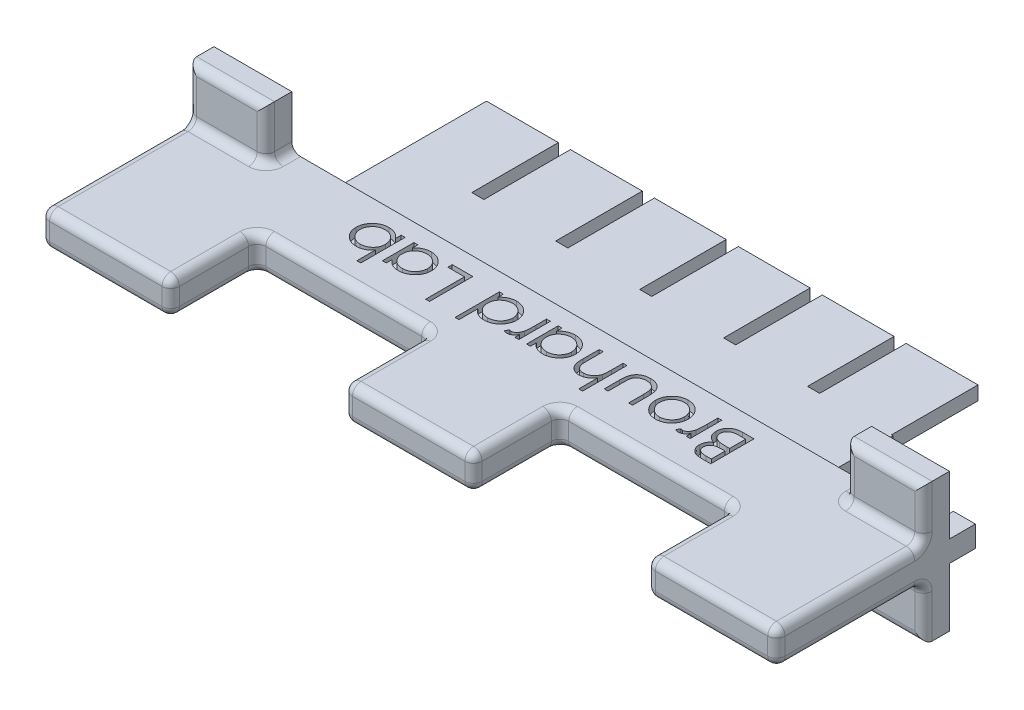
from build123d import *

# Parameters (mm, degrees)
SKETCH1_W           = 85
SKETCH1_H           = 4
BOSS_EXTRUDE1_DEPTH = 10
SKETCH2_W           = 15
SKETCH2_H           = 4
BOSS_EXTRUDE2_DEPTH = 10
SKETCH3_W           = 2.55
SKETCH3_H           = 2.45
BOSS_EXTRUDE3_DEPTH = 3
SKETCH4_W           = 57
SKETCH4_H           = 1.6
BOSS_EXTRUDE4_DEPTH = 7.5
SKETCH6_W           = 9
SKETCH6_H           = 6
BOSS_EXTRUDE6_DEPTH = 3
FILLET1_R           = 1
CUT_EXTRUDE1_DEPTH  = 1
SKETCH5_W           = 8.3
SKETCH5_H           = 1.6
BOSS_EXTRUDE5_DEPTH = 10


with BuildPart() as part:
    # Sketch1 → Boss-Extrude1 (new body)
    with BuildSketch(Plane.XY):
        Rectangle(SKETCH1_W, SKETCH1_H)
    extrude(amount=BOSS_EXTRUDE1_DEPTH)

    # Sketch2 → Boss-Extrude2 (add)
    with BuildSketch(Plane.XY.offset(10)):
        with Locations((-35, 0)):
            Rectangle(SKETCH2_W, SKETCH2_H)
        with Locations((35, 0)):
            Rectangle(SKETCH2_W, SKETCH2_H)
        Rectangle(SKETCH2_W, SKETCH2_H)
    extrude(amount=BOSS_EXTRUDE2_DEPTH)

    # Sketch3 → Boss-Extrude3 (add)
    with BuildSketch(Plane(origin=(0, 0, 0), x_dir=(-1, 0, 0), z_dir=(0, 0, -1))):
        with Locations((-41.225, 0)):
            Rectangle(SKETCH3_W, SKETCH3_H)
        with Locations((41.225, 0)):
            Rectangle(SKETCH3_W, SKETCH3_H)
    extrude(amount=BOSS_EXTRUDE3_DEPTH)

    # Sketch4 → Boss-Extrude4 (add)
    with BuildSketch(Plane(origin=(0, 0, 0), x_dir=(-1, 0, 0), z_dir=(0, 0, -1))):
        Rectangle(SKETCH4_W, SKETCH4_H)
    extrude(amount=BOSS_EXTRUDE4_DEPTH)

    # Sketch6 → Boss-Extrude6 (add)
    with BuildSketch(Plane(origin=(0, 0, 0), x_dir=(-1, 0, 0), z_dir=(0, 0, -1))):
        with Locations((38, -5)):
            Rectangle(SKETCH6_W, SKETCH6_H)
        with Locations((38, 5)):
            Rectangle(SKETCH6_W, SKETCH6_H)
        with Locations((-38, -5)):
            Rectangle(SKETCH6_W, SKETCH6_H)
        with Locations((-38, 5)):
            Rectangle(SKETCH6_W, SKETCH6_H)
    extrude(amount=-BOSS_EXTRUDE6_DEPTH)

    # Fillet1
    fillet1_edges = [part.edges().sort_by_distance(p)[0] for p in [
        (-42.5, 5, 3),
        (-38, 2, 3),
        (-33.5, 5, 3),
        (-33.5, 2, 1.5),
        (-38, 8, 3),
        (42.5, -5, 3),
        (38, -2, 3),
        (33.5, -5, 3),
        (33.5, -2, 1.5),
        (38, -8, 3),
        (42.5, 5, 3),
        (38, 8, 3),
        (33.5, 5, 3),
        (38, 2, 3),
        (33.5, 2, 1.5),
        (-17.5, -2, 10),
        (-27.5, 0, 10),
        (-27.5, -2, 15),
        (-27.5, 2, 15),
        (-42.5, 0, 20),
        (-35, -2, 20),
        (-27.5, 0, 20),
        (-35, 2, 20),
        (17.5, 2, 10),
        (27.5, 0, 10),
        (27.5, 2, 15),
        (27.5, -2, 15),
        (42.5, 0, 20),
        (35, 2, 20),
        (27.5, 0, 20),
        (35, -2, 20),
        (17.5, -2, 10),
        (-17.5, 2, 10),
        (7.5, 0, 10),
        (7.5, -2, 15),
        (7.5, 2, 15),
        (-7.5, 0, 10),
        (-7.5, 2, 15),
        (-7.5, -2, 15),
        (7.5, 0, 20),
        (0, 2, 20),
        (-7.5, 0, 20),
        (0, -2, 20),
        (42.5, -2, 11.5),
        (-42.5, -2, 11.5),
        (-42.5, 2, 11.5),
        (42.5, 2, 11.5),
        (-42.5, -5, 3),
        (-38, -8, 3),
        (-33.5, -5, 3),
        (-38, -2, 3),
        (-33.5, -2, 1.5),
    ]]
    fillet(fillet1_edges, radius=FILLET1_R)

    # Sketch8 → Cut-Extrude1 (cut)
    with BuildSketch(Plane(origin=(0, 2, 0), x_dir=(1, 0, 0), z_dir=(0, 1, 0))):
        with BuildLine():
            Line((21.955128205, -7.045024133), (20.979567308, -7.045024133))
            add(Edge.make_bspline(
                [(20.979567308, -7.045024133), (20.931811586, -7.044777014), (20.839249111, -7.044298035), (20.704660144, -7.036696988), (20.578554958, -7.026592114), (20.461156398, -7.009641733), (20.351700568, -6.992066423), (20.251298675, -6.966270076), (20.159109728, -6.937777071), (20.048409672, -6.893936716), (19.92280529, -6.825852091), (19.787804083, -6.724876123), (19.670452795, -6.603814091), (19.570669416, -6.465854357), (19.490591132, -6.314083016), (19.43339094, -6.151765477), (19.396643358, -5.981632539), (19.392911608, -5.864990679), (19.391025641, -5.806041761)],
                knots=[0, 0, 0, 0, 0.000143243, 0.000277641, 0.000404323, 0.000522601, 0.000633422, 0.000736665, 0.000833282, 0.000922745, 0.001093491, 0.001260157, 0.001426607, 0.001597303, 0.001769346, 0.001939468, 0.002112331, 0.002288957, 0.002288957, 0.002288957, 0.002288957], degree=3))
            add(Edge.make_bspline(
                [(19.391025641, -5.806041761), (19.392566125, -5.750816773), (19.395593321, -5.642294463), (19.425166581, -5.484100137), (19.4698067, -5.333038737), (19.534225102, -5.190566035), (19.616363978, -5.057933935), (19.716298264, -4.937404803), (19.834792937, -4.831345021), (19.923759393, -4.772321243), (19.968950321, -4.742339838)],
                knots=[0, 0, 0, 0, 0.00016551, 0.000325243, 0.000481139, 0.000637145, 0.000792791, 0.000947835, 0.001105294, 0.001267844, 0.001267844, 0.001267844, 0.001267844], degree=3))
            add(Edge.make_bspline(
                [(19.968950321, -4.742339838), (19.912145679, -4.720542475), (19.803464327, -4.678838718), (19.653711211, -4.604821394), (19.524645211, -4.524933301), (19.41460302, -4.438588883), (19.32239544, -4.34296875), (19.240253224, -4.240591123), (19.170541651, -4.127890536), (19.111062126, -4.007309158), (19.063944891, -3.879485542), (19.031238978, -3.745375962), (19.010496783, -3.606499394), (19.007784363, -3.512111636), (19.006410256, -3.464294967)],
                knots=[0, 0, 0, 0, 0.000182459, 0.00034909, 0.000500276, 0.000637148, 0.000767471, 0.00089793, 0.001030217, 0.001164151, 0.001300726, 0.001437979, 0.001577644, 0.001721044, 0.001721044, 0.001721044, 0.001721044], degree=3))
            add(Edge.make_bspline(
                [(19.006410256, -3.464294967), (19.007805885, -3.41548523), (19.010551822, -3.319450707), (19.030807012, -3.178370784), (19.065112767, -3.043553694), (19.112331393, -2.914102037), (19.173883248, -2.790773975), (19.248244287, -2.672600284), (19.337493216, -2.561332318), (19.437996289, -2.45535544), (19.550128803, -2.358444164), (19.673690061, -2.2751618), (19.805513315, -2.203227398), (19.947403728, -2.145396174), (20.098354491, -2.100124903), (20.258400966, -2.068824422), (20.427452272, -2.047649449), (20.543467886, -2.045914087), (20.602964744, -2.045024133)],
                knots=[0, 0, 0, 0, 0.000146402, 0.00028805, 0.000426518, 0.000563092, 0.000700608, 0.000839267, 0.000981145, 0.001127794, 0.001276955, 0.001424748, 0.00157399, 0.001726698, 0.001883553, 0.002046002, 0.002215459, 0.002393845, 0.002393845, 0.002393845, 0.002393845], degree=3))
            Line((20.602964744, -2.045024133), (21.955128205, -2.045024133))
            Line((21.955128205, -2.045024133), (21.955128205, -7.045024133))
        make_face()
        with BuildLine():
            Line((21.506410256, -6.53220362), (21.506410256, -4.929639518))
            Line((21.506410256, -4.929639518), (21.204927885, -4.929639518))
            add(Edge.make_bspline(
                [(21.204927885, -4.929639518), (21.16085778, -4.930206082), (21.075705357, -4.9313008), (20.952063514, -4.934535484), (20.837581625, -4.943196106), (20.731865233, -4.952356158), (20.635622811, -4.966460704), (20.548532434, -4.983720889), (20.469810894, -5.00181496), (20.379071632, -5.032675643), (20.276157749, -5.077807077), (20.16721677, -5.149562501), (20.069164992, -5.232639769), (19.988277934, -5.331182392), (19.920936523, -5.437599512), (19.875598165, -5.552684686), (19.843986577, -5.672472047), (19.841172407, -5.755083607), (19.83974359, -5.797027338)],
                knots=[0, 0, 0, 0, 0.000132227, 0.000255489, 0.000370952, 0.000476596, 0.000573767, 0.000662554, 0.000742964, 0.000815812, 0.000949851, 0.001078759, 0.001205868, 0.001333854, 0.001459773, 0.001581973, 0.001703679, 0.001829203, 0.001829203, 0.001829203, 0.001829203], degree=3))
            add(Edge.make_bspline(
                [(19.83974359, -5.797027338), (19.840440447, -5.824795004), (19.841807408, -5.879264312), (19.85469429, -5.958622966), (19.872478035, -6.034141042), (19.901807859, -6.103782707), (19.936556119, -6.169993364), (19.98109509, -6.230681546), (20.03245262, -6.287491301), (20.092329064, -6.338899898), (20.160479658, -6.385396007), (20.239063252, -6.424101797), (20.325943351, -6.458499162), (20.422931675, -6.48457317), (20.528096305, -6.507209559), (20.643041681, -6.521483941), (20.767075062, -6.530654029), (20.853013063, -6.531675569), (20.897435897, -6.53220362)],
                knots=[0, 0, 0, 0, 8.3229e-05, 0.000163264, 0.000240757, 0.000315341, 0.000389283, 0.000464617, 0.000540481, 0.000618594, 0.000700823, 0.000787274, 0.000880832, 0.000980716, 0.001088168, 0.001203335, 0.00132786, 0.001461107, 0.001461107, 0.001461107, 0.001461107], degree=3))
            Line((20.897435897, -6.53220362), (21.506410256, -6.53220362))
        make_face(mode=Mode.SUBTRACT)
        with BuildLine():
            Line((21.506410256, -4.416819005), (21.506410256, -2.557844646))
            Line((21.506410256, -2.557844646), (20.867387821, -2.557844646))
            add(Edge.make_bspline(
                [(20.867387821, -2.557844646), (20.82165107, -2.558445571), (20.733499514, -2.559603775), (20.606126985, -2.562352033), (20.48869926, -2.57254806), (20.380238634, -2.582323383), (20.281246941, -2.598293401), (20.190761319, -2.61375789), (20.110848501, -2.63651465), (20.017345889, -2.667828353), (19.912764158, -2.717871803), (19.798555972, -2.791464981), (19.697962318, -2.881106895), (19.612615651, -2.984324471), (19.541653639, -3.095395221), (19.492561941, -3.214537751), (19.460753316, -3.337772506), (19.457007017, -3.422035912), (19.455128205, -3.464294967)],
                knots=[0, 0, 0, 0, 0.000137234, 0.000264501, 0.000382034, 0.000490767, 0.000591058, 0.000682796, 0.000765899, 0.000840017, 0.000978463, 0.001112367, 0.001246451, 0.001380849, 0.001513136, 0.001640186, 0.001766022, 0.001892621, 0.001892621, 0.001892621, 0.001892621], degree=3))
            add(Edge.make_bspline(
                [(19.455128205, -3.464294967), (19.455511728, -3.490717987), (19.456272588, -3.543137822), (19.468232548, -3.620102651), (19.484829912, -3.695025725), (19.509289766, -3.766889341), (19.538879538, -3.836930979), (19.577915987, -3.902871611), (19.621948812, -3.967518228), (19.690148998, -4.050208407), (19.790699472, -4.144331407), (19.933635519, -4.235332182), (20.095250073, -4.309910154), (20.212743455, -4.341437989), (20.2734375, -4.357724454)],
                knots=[0, 0, 0, 0, 7.9184e-05, 0.00015709, 0.000233139, 0.000309156, 0.000384516, 0.000460796, 0.000538586, 0.000618995, 0.000781989, 0.000949233, 0.001125381, 0.001313608, 0.001313608, 0.001313608, 0.001313608], degree=3))
            add(Edge.make_bspline(
                [(20.2734375, -4.357724454), (20.297764757, -4.36266062), (20.350511268, -4.373363246), (20.436522534, -4.384653585), (20.535045896, -4.394781387), (20.645660247, -4.402076233), (20.768805516, -4.409907124), (20.904442139, -4.412844185), (21.052666008, -4.416429024), (21.15551238, -4.416685686), (21.208934295, -4.416819005)],
                knots=[0, 0, 0, 0, 7.4449e-05, 0.000161422, 0.000260089, 0.000371555, 0.000493951, 0.000630228, 0.000778496, 0.000938755, 0.000938755, 0.000938755, 0.000938755], degree=3))
            Line((21.208934295, -4.416819005), (21.506410256, -4.416819005))
        make_face(mode=Mode.SUBTRACT)
        with BuildLine():
            Line((18.237179487, -5.698870287), (17.788461538, -5.698870287))
            Line((17.788461538, -5.698870287), (17.788461538, -5.16100971))
            add(Edge.make_bspline(
                [(17.788461538, -5.16100971), (17.755359908, -5.211117117), (17.692053298, -5.306947144), (17.586273377, -5.43343718), (17.479111393, -5.53983342), (17.366921794, -5.622588498), (17.252557594, -5.685650706), (17.136357118, -5.730343447), (17.017481778, -5.757585182), (16.937237879, -5.761174556), (16.897035256, -5.762972851)],
                knots=[0, 0, 0, 0, 0.000180032, 0.00034431, 0.000493764, 0.000631989, 0.000761087, 0.000884414, 0.00100446, 0.00112499, 0.00112499, 0.00112499, 0.00112499], degree=3))
            add(Edge.make_bspline(
                [(16.897035256, -5.762972851), (16.865844687, -5.761310147), (16.801992924, -5.757906343), (16.705041331, -5.732794344), (16.604739598, -5.694222955), (16.540012887, -5.657063647), (16.506410256, -5.637772531)],
                knots=[0, 0, 0, 0, 9.3493e-05, 0.000191394, 0.000298902, 0.000414971, 0.000414971, 0.000414971, 0.000414971], degree=3))
            Line((16.506410256, -5.637772531), (16.752804487, -5.249150736))
            add(Edge.make_bspline(
                [(16.752804487, -5.249150736), (16.774388803, -5.258779687), (16.815359967, -5.277057281), (16.875295061, -5.298688724), (16.930554114, -5.311425747), (16.965759197, -5.313355343), (16.982171474, -5.314254902)],
                knots=[0, 0, 0, 0, 7.0888e-05, 0.000134558, 0.000190943, 0.000240184, 0.000240184, 0.000240184, 0.000240184], degree=3))
            add(Edge.make_bspline(
                [(16.982171474, -5.314254902), (17.018552318, -5.311962095), (17.092095887, -5.307327204), (17.199553418, -5.267726819), (17.305221395, -5.20820996), (17.387285817, -5.138004944), (17.451536641, -5.071852679), (17.497773588, -5.013639038), (17.539299542, -4.947803919), (17.579572406, -4.876841023), (17.616991286, -4.798984205), (17.65042989, -4.714102186), (17.681701622, -4.622897124), (17.699312387, -4.559480067), (17.708333333, -4.526995287)],
                knots=[0, 0, 0, 0, 0.000108839, 0.000220017, 0.000339778, 0.000471355, 0.000542193, 0.000616339, 0.000693851, 0.000775474, 0.000861039, 0.000952734, 0.001049023, 0.001150145, 0.001150145, 0.001150145, 0.001150145], degree=3))
            add(Edge.make_bspline(
                [(17.708333333, -4.526995287), (17.715105579, -4.4980295), (17.73018081, -4.433550753), (17.744447085, -4.325868753), (17.75911049, -4.198727857), (17.769124119, -4.051980366), (17.778583328, -3.885062178), (17.783808984, -3.698693379), (17.788295276, -3.492361731), (17.78840435, -3.348446216), (17.788461538, -3.272988877)],
                knots=[0, 0, 0, 0, 8.9193e-05, 0.000198547, 0.000325526, 0.000473173, 0.000639683, 0.000827079, 0.001032447, 0.001258811, 0.001258811, 0.001258811, 0.001258811], degree=3))
            Line((17.788461538, -3.272988877), (17.788461538, -2.045024133))
            Line((17.788461538, -2.045024133), (18.237179487, -2.045024133))
            Line((18.237179487, -2.045024133), (18.237179487, -5.698870287))
        make_face()
        with BuildLine():
            add(Edge.make_bspline(
                [(14.29286859, -5.762972851), (14.224307927, -5.761517291), (14.089877222, -5.758663293), (13.893032913, -5.728009819), (13.705327588, -5.681525783), (13.525956048, -5.616093456), (13.356402056, -5.530243686), (13.195151776, -5.426425769), (13.042528278, -5.303937317), (12.951070622, -5.209132095), (12.904647436, -5.16100971)],
                knots=[0, 0, 0, 0, 0.000205526, 0.000402987, 0.000596112, 0.000784972, 0.000974447, 0.001165038, 0.001359476, 0.001559909, 0.001559909, 0.001559909, 0.001559909], degree=3))
            add(Edge.make_bspline(
                [(12.904647436, -5.16100971), (12.864673216, -5.11498973), (12.785498387, -5.023840384), (12.683975931, -4.876046652), (12.59651656, -4.722989365), (12.526426616, -4.562636041), (12.471162296, -4.396386511), (12.431925587, -4.223669352), (12.408587109, -4.044865999), (12.405440013, -3.923431945), (12.403846154, -3.861931185)],
                knots=[0, 0, 0, 0, 0.000182745, 0.000361954, 0.000536876, 0.000710881, 0.000886036, 0.001061708, 0.001241475, 0.001425944, 0.001425944, 0.001425944, 0.001425944], degree=3))
            add(Edge.make_bspline(
                [(12.403846154, -3.861931185), (12.405248064, -3.800073959), (12.408018305, -3.677841197), (12.434223472, -3.497813533), (12.474982163, -3.323249495), (12.533313369, -3.154879952), (12.608110636, -2.992190127), (12.699383171, -2.835891045), (12.807770716, -2.685672654), (12.930635425, -2.542816985), (13.066416897, -2.411135675), (13.21375075, -2.296436369), (13.369848434, -2.197755629), (13.536840837, -2.119375683), (13.712350874, -2.056195988), (13.8974949, -2.012629522), (14.09210775, -1.986052796), (14.225006973, -1.982656037), (14.29286859, -1.980921569)],
                knots=[0, 0, 0, 0, 0.00018547, 0.000366497, 0.000544574, 0.000722589, 0.000900065, 0.001080956, 0.001264689, 0.001455025, 0.001645575, 0.001831106, 0.002014249, 0.002198383, 0.002383395, 0.002572886, 0.002767942, 0.002971467, 0.002971467, 0.002971467, 0.002971467], degree=3))
            add(Edge.make_bspline(
                [(14.29286859, -1.980921569), (14.361059424, -1.982670388), (14.494614618, -1.986095539), (14.689960267, -2.012431829), (14.875883807, -2.056661478), (15.052224048, -2.118593533), (15.219215773, -2.198399418), (15.37588985, -2.296052412), (15.523293198, -2.411193757), (15.65911724, -2.542801247), (15.781970535, -2.685676709), (15.890361026, -2.835889993), (15.981632796, -2.992190401), (16.056430263, -3.154879879), (16.114761415, -3.323249515), (16.155520121, -3.497813528), (16.181725284, -3.677841198), (16.184495525, -3.80007396), (16.185897436, -3.861931185)],
                knots=[0, 0, 0, 0, 0.000204526, 0.000400574, 0.000590065, 0.000776965, 0.000960195, 0.001144188, 0.00132972, 0.001520269, 0.001710605, 0.001894339, 0.00207523, 0.002252706, 0.002430721, 0.002608798, 0.002789825, 0.002975294, 0.002975294, 0.002975294, 0.002975294], degree=3))
            add(Edge.make_bspline(
                [(16.185897436, -3.861931185), (16.184296519, -3.923099043), (16.18112698, -4.044200892), (16.157756652, -4.22264832), (16.118946868, -4.394836864), (16.062916427, -4.560178538), (15.992956591, -4.720146456), (15.90637746, -4.873764934), (15.803872945, -5.02091287), (15.725005709, -5.111941341), (15.685096154, -5.158004902)],
                knots=[0, 0, 0, 0, 0.000183468, 0.000363236, 0.000538908, 0.000712162, 0.000886167, 0.001061962, 0.001240348, 0.001423094, 0.001423094, 0.001423094, 0.001423094], degree=3))
            add(Edge.make_bspline(
                [(15.685096154, -5.158004902), (15.638739114, -5.20653651), (15.547569839, -5.301982456), (15.394241809, -5.424229232), (15.233685171, -5.529446865), (15.063037498, -5.615253429), (14.883167202, -5.681407061), (14.694066814, -5.728226774), (14.496506031, -5.758527704), (14.361424213, -5.761476369), (14.29286859, -5.762972851)],
                knots=[0, 0, 0, 0, 0.00020114, 0.000395577, 0.000586713, 0.000776188, 0.000967274, 0.001160399, 0.001359841, 0.001565367, 0.001565367, 0.001565367, 0.001565367], degree=3))
        make_face()
        with BuildLine():
            add(Edge.make_bspline(
                [(14.294871795, -5.314254902), (14.343354042, -5.31287684), (14.439066976, -5.310156289), (14.579952881, -5.289466071), (14.715578773, -5.256679949), (14.84621924, -5.210117374), (14.971369132, -5.149920796), (15.091165691, -5.076401027), (15.205288814, -4.989167289), (15.312855022, -4.88995037), (15.412753003, -4.782192755), (15.499001382, -4.666286529), (15.572889716, -4.545452386), (15.633262525, -4.419007361), (15.679580189, -4.286604065), (15.712397714, -4.149000046), (15.733127199, -4.005785755), (15.735814091, -3.908409845), (15.737179487, -3.858926377)],
                knots=[0, 0, 0, 0, 0.000145402, 0.00028705, 0.000426247, 0.000563423, 0.000702299, 0.000842129, 0.000984361, 0.00113252, 0.001280679, 0.00142451, 0.001565195, 0.001704975, 0.001844039, 0.001985183, 0.002128814, 0.002277217, 0.002277217, 0.002277217, 0.002277217], degree=3))
            add(Edge.make_bspline(
                [(15.737179487, -3.858926377), (15.734890082, -3.794992084), (15.730346041, -3.668094469), (15.693206633, -3.48126298), (15.631516344, -3.301562306), (15.546449569, -3.131156088), (15.441687276, -2.973216762), (15.31918926, -2.831196974), (15.177261944, -2.710573578), (15.020738225, -2.609127271), (14.851836243, -2.5292384), (14.673387712, -2.471947456), (14.487017459, -2.435206285), (14.359480893, -2.431511347), (14.294871795, -2.429639518)],
                knots=[0, 0, 0, 0, 0.000191683, 0.000380455, 0.000568919, 0.000760186, 0.000950198, 0.001136194, 0.00132088, 0.001507019, 0.001694298, 0.001879594, 0.002068178, 0.002261801, 0.002261801, 0.002261801, 0.002261801], degree=3))
            add(Edge.make_bspline(
                [(14.294871795, -2.429639518), (14.23025898, -2.431500504), (14.102715078, -2.435174039), (13.916085515, -2.472133599), (13.737147914, -2.528989279), (13.568070317, -2.609217501), (13.411475317, -2.710190138), (13.270561459, -2.831884154), (13.147008507, -2.972843418), (13.04214248, -3.130946672), (12.958446366, -3.301827223), (12.896465966, -3.481229869), (12.859415628, -3.668102902), (12.854859565, -3.794994909), (12.852564103, -3.858926377)],
                knots=[0, 0, 0, 0, 0.000193623, 0.000382206, 0.000568456, 0.000755734, 0.000941873, 0.001125801, 0.001312456, 0.001502468, 0.001693291, 0.001881755, 0.002070527, 0.00226221, 0.00226221, 0.00226221, 0.00226221], degree=3))
            add(Edge.make_bspline(
                [(12.852564103, -3.858926377), (12.85391927, -3.908413822), (12.856586033, -4.00579756), (12.877461924, -4.148954918), (12.909764333, -4.286878115), (12.958078967, -4.418473367), (13.016348399, -4.546067931), (13.092028067, -4.665924648), (13.177874936, -4.782266279), (13.277956043, -4.889885455), (13.385510177, -4.98952979), (13.500490643, -5.076083255), (13.620342842, -5.149962779), (13.745532283, -5.210124787), (13.875877117, -5.256500729), (14.011091241, -5.289608892), (14.151353237, -5.310080851), (14.246726302, -5.312854653), (14.294871795, -5.314254902)],
                knots=[0, 0, 0, 0, 0.000148403, 0.000292034, 0.000433178, 0.000572578, 0.00071193, 0.000853138, 0.000996969, 0.001145128, 0.001293287, 0.001436317, 0.001576147, 0.001715023, 0.001852199, 0.001990424, 0.002132072, 0.002276473, 0.002276473, 0.002276473, 0.002276473], degree=3))
        make_face(mode=Mode.SUBTRACT)
        with BuildLine():
            Line((11.570512821, -5.698870287), (11.121794872, -5.698870287))
            Line((11.121794872, -5.698870287), (11.121794872, -4.004158749))
            add(Edge.make_bspline(
                [(11.121794872, -4.004158749), (11.121592151, -3.954411964), (11.121204354, -3.859248695), (11.118574439, -3.722312714), (11.112388591, -3.597431696), (11.104654555, -3.484533501), (11.094708647, -3.383637227), (11.082875275, -3.295095289), (11.069648958, -3.217903597), (11.056702224, -3.171413089), (11.05068109, -3.149791761)],
                knots=[0, 0, 0, 0, 0.000149242, 0.000285493, 0.000410838, 0.000524302, 0.000624962, 0.000714911, 0.000792314, 0.000859608, 0.000859608, 0.000859608, 0.000859608], degree=3))
            add(Edge.make_bspline(
                [(11.05068109, -3.149791761), (11.041021805, -3.122616307), (11.02190405, -3.06883037), (10.987228565, -2.991130691), (10.944327515, -2.919170094), (10.897397624, -2.850149082), (10.843207537, -2.786203671), (10.78254961, -2.72691621), (10.716500508, -2.671595092), (10.619751651, -2.6048734), (10.487494763, -2.534263345), (10.314242396, -2.472488378), (10.126045943, -2.436112097), (9.995820794, -2.431836921), (9.928886218, -2.429639518)],
                knots=[0, 0, 0, 0, 8.6516e-05, 0.000171232, 0.000254721, 0.000337515, 0.000421387, 0.00050567, 0.000591721, 0.00067952, 0.000857864, 0.001039709, 0.001229465, 0.001430146, 0.001430146, 0.001430146, 0.001430146], degree=3))
            add(Edge.make_bspline(
                [(9.928886218, -2.429639518), (9.86194316, -2.431828713), (9.732748927, -2.436053669), (9.546518851, -2.471939165), (9.375968682, -2.530483395), (9.223089747, -2.613350563), (9.088841758, -2.714376404), (8.976981124, -2.832969142), (8.884684323, -2.965323174), (8.844385248, -3.064072442), (8.82411859, -3.113734069)],
                knots=[0, 0, 0, 0, 0.000200681, 0.000387296, 0.000566586, 0.000739571, 0.000906841, 0.001068376, 0.001227003, 0.001387484, 0.001387484, 0.001387484, 0.001387484], degree=3))
            add(Edge.make_bspline(
                [(8.82411859, -3.113734069), (8.8181224, -3.1336855), (8.80486629, -3.177793242), (8.790725551, -3.252630176), (8.777460105, -3.341789135), (8.768616165, -3.446206446), (8.758522511, -3.564961319), (8.755037146, -3.698667884), (8.750059864, -3.846538026), (8.750020544, -3.950065981), (8.75, -4.004158749)],
                knots=[0, 0, 0, 0, 6.2462e-05, 0.000138088, 0.000228176, 0.000332823, 0.000452355, 0.000585662, 0.000733953, 0.000896216, 0.000896216, 0.000896216, 0.000896216], degree=3))
            Line((8.75, -4.004158749), (8.75, -5.698870287))
            Line((8.75, -5.698870287), (8.301282051, -5.698870287))
            Line((8.301282051, -5.698870287), (8.301282051, -3.920024133))
            add(Edge.make_bspline(
                [(8.301282051, -3.920024133), (8.30191531, -3.859585653), (8.303143917, -3.742326733), (8.310980731, -3.571916291), (8.324614367, -3.412799073), (8.344773775, -3.265462167), (8.369229918, -3.129870336), (8.400154934, -3.00598092), (8.437277048, -2.893621613), (8.479165629, -2.791153018), (8.528529202, -2.698158121), (8.581390514, -2.610389295), (8.640827886, -2.528135886), (8.705652894, -2.450645369), (8.777741804, -2.379798189), (8.85333008, -2.311961845), (8.93610888, -2.251321381), (9.023288539, -2.194646502), (9.117066908, -2.144351467), (9.216637391, -2.100832577), (9.321894658, -2.063022013), (9.433003103, -2.033803946), (9.549897573, -2.009153726), (9.67242881, -1.992746928), (9.800829998, -1.982271357), (9.888132562, -1.981379054), (9.932892628, -1.980921569)],
                knots=[0, 0, 0, 0, 0.000181315, 0.000351776, 0.000511647, 0.000660239, 0.000797754, 0.000924804, 0.001042946, 0.001152506, 0.001256441, 0.001358477, 0.001459659, 0.001560587, 0.001661157, 0.001762636, 0.001865001, 0.001968632, 0.00207439, 0.002183817, 0.002294379, 0.002409546, 0.002528193, 0.002652561, 0.002780158, 0.002914407, 0.002914407, 0.002914407, 0.002914407], degree=3))
            add(Edge.make_bspline(
                [(9.932892628, -1.980921569), (9.977316456, -1.981406186), (10.064613414, -1.982358504), (10.192711845, -1.992570693), (10.315507575, -2.00940504), (10.432494069, -2.033606354), (10.544142851, -2.063257518), (10.649911875, -2.100566743), (10.749934706, -2.144600485), (10.84442655, -2.194693497), (10.933073912, -2.251115088), (11.015677547, -2.313213364), (11.093710062, -2.379368112), (11.165005381, -2.451835522), (11.23008642, -2.530073038), (11.28923533, -2.613729086), (11.343463789, -2.701858176), (11.392537938, -2.79623559), (11.434697953, -2.899909467), (11.471919623, -3.014619732), (11.502363426, -3.141623289), (11.527138371, -3.28081177), (11.547069003, -3.431518969), (11.560906348, -3.594616706), (11.568643249, -3.769707694), (11.569876194, -3.890636109), (11.570512821, -3.953077018)],
                knots=[0, 0, 0, 0, 0.000133247, 0.000261843, 0.000385219, 0.000504847, 0.000620013, 0.00073152, 0.000840947, 0.000947589, 0.001052063, 0.001155829, 0.001257407, 0.001358687, 0.001460383, 0.00156238, 0.001665793, 0.001770617, 0.001881102, 0.002001148, 0.002132087, 0.002272558, 0.00242512, 0.002587985, 0.002763448, 0.002950772, 0.002950772, 0.002950772, 0.002950772], degree=3))
            Line((11.570512821, -3.953077018), (11.570512821, -5.698870287))
        make_face()
        with BuildLine():
            Line((7.275641026, -7.173229261), (6.826923077, -7.173229261))
            Line((6.826923077, -7.173229261), (6.826923077, -5.00876612))
            add(Edge.make_bspline(
                [(6.826923077, -5.00876612), (6.778678808, -5.068888094), (6.684893793, -5.185762911), (6.528113976, -5.339904506), (6.36474826, -5.471196487), (6.193410264, -5.578408978), (6.014828183, -5.661579829), (5.828563194, -5.719766634), (5.635090167, -5.756050633), (5.503296595, -5.760649137), (5.436698718, -5.762972851)],
                knots=[0, 0, 0, 0, 0.000231093, 0.000449235, 0.000658061, 0.000858722, 0.001054107, 0.001247341, 0.001442817, 0.001642498, 0.001642498, 0.001642498, 0.001642498], degree=3))
            add(Edge.make_bspline(
                [(5.436698718, -5.762972851), (5.369051259, -5.760620551), (5.236582495, -5.756014225), (5.044402774, -5.715426657), (4.863656734, -5.651196128), (4.696758785, -5.560924861), (4.546286047, -5.448841659), (4.415775284, -5.31738737), (4.306291209, -5.168293369), (4.233038251, -5.029320354), (4.185028125, -4.905733149), (4.154679673, -4.799671692), (4.128934509, -4.68150037), (4.106507375, -4.551264166), (4.091559078, -4.408342759), (4.079552578, -4.253379458), (4.071014758, -4.086383599), (4.070683898, -3.970783239), (4.070512821, -3.91100971)],
                knots=[0, 0, 0, 0, 0.000202742, 0.000397014, 0.000586474, 0.000776485, 0.000963986, 0.001147421, 0.001330122, 0.001516953, 0.001616837, 0.001727454, 0.0018475, 0.00197956, 0.002123683, 0.002278397, 0.002445857, 0.002625155, 0.002625155, 0.002625155, 0.002625155], degree=3))
            Line((4.070512821, -3.91100971), (4.070512821, -2.045024133))
            Line((4.070512821, -2.045024133), (4.519230769, -2.045024133))
            Line((4.519230769, -2.045024133), (4.519230769, -3.763774133))
            add(Edge.make_bspline(
                [(4.519230769, -3.763774133), (4.519501544, -3.813520868), (4.52001949, -3.908677905), (4.521752659, -4.044914373), (4.525533642, -4.16814974), (4.531869413, -4.278639822), (4.53824468, -4.376234881), (4.547283145, -4.46109433), (4.557720701, -4.532685817), (4.567105279, -4.575778103), (4.571314103, -4.595104261)],
                knots=[0, 0, 0, 0, 0.000149242, 0.000285475, 0.000408737, 0.000519077, 0.000617484, 0.0007021, 0.000775053, 0.000834376, 0.000834376, 0.000834376, 0.000834376], degree=3))
            add(Edge.make_bspline(
                [(4.571314103, -4.595104261), (4.587558684, -4.651851981), (4.618706291, -4.760660919), (4.692549434, -4.908198617), (4.782632802, -5.035130852), (4.894290172, -5.137852366), (5.023812243, -5.21879062), (5.172428658, -5.273933897), (5.338240367, -5.309099366), (5.454866892, -5.312485195), (5.515825321, -5.314254902)],
                knots=[0, 0, 0, 0, 0.000176748, 0.000338899, 0.000492364, 0.000641202, 0.000791008, 0.00094763, 0.001114405, 0.001297029, 0.001297029, 0.001297029, 0.001297029], degree=3))
            add(Edge.make_bspline(
                [(5.515825321, -5.314254902), (5.551925349, -5.313584935), (5.623366372, -5.312259087), (5.729246241, -5.298610846), (5.8322736, -5.277055291), (5.932171925, -5.245215815), (6.029144995, -5.206505033), (6.123586995, -5.15899916), (6.21420543, -5.101559446), (6.302169918, -5.036911618), (6.384056208, -4.965394032), (6.460236741, -4.889895628), (6.528148933, -4.809503542), (6.589675418, -4.725503187), (6.642787274, -4.636743532), (6.689148815, -4.544080206), (6.728485525, -4.44739143), (6.748032228, -4.380284199), (6.7578125, -4.346706826)],
                knots=[0, 0, 0, 0, 0.000108247, 0.000214218, 0.000319711, 0.000423617, 0.000528331, 0.0006327, 0.00074025, 0.000849828, 0.000959881, 0.001066117, 0.001171281, 0.001275259, 0.001378152, 0.001481176, 0.00158589, 0.001690753, 0.001690753, 0.001690753, 0.001690753], degree=3))
            add(Edge.make_bspline(
                [(6.7578125, -4.346706826), (6.763440253, -4.322391181), (6.77570382, -4.2694044), (6.789010725, -4.182012509), (6.800921863, -4.080460549), (6.81099122, -3.964902548), (6.817167057, -3.834915059), (6.823821687, -3.691385118), (6.82629885, -3.533413659), (6.826708783, -3.423562934), (6.826923077, -3.366137915)],
                knots=[0, 0, 0, 0, 7.4853e-05, 0.000163113, 0.000264986, 0.000381603, 0.000511, 0.000655356, 0.000812636, 0.000984915, 0.000984915, 0.000984915, 0.000984915], degree=3))
            Line((6.826923077, -3.366137915), (6.826923077, -2.045024133))
            Line((6.826923077, -2.045024133), (7.275641026, -2.045024133))
            Line((7.275641026, -2.045024133), (7.275641026, -7.173229261))
        make_face()
        with BuildLine():
            Line((-0.673076923, -5.698870287), (-0.673076923, -2.045024133))
            Line((-0.673076923, -2.045024133), (-0.224358974, -2.045024133))
            Line((-0.224358974, -2.045024133), (-0.224358974, -2.677035351))
            add(Edge.make_bspline(
                [(-0.224358974, -2.677035351), (-0.173692153, -2.619914798), (-0.074668173, -2.508277549), (0.089136249, -2.361533046), (0.264203306, -2.241723382), (0.447550404, -2.144473643), (0.640596711, -2.07116495), (0.842208477, -2.019519884), (1.052227954, -1.985924035), (1.195449856, -1.982604018), (1.268028846, -1.980921569)],
                knots=[0, 0, 0, 0, 0.000228947, 0.000447457, 0.00065777, 0.000863866, 0.001068669, 0.001275649, 0.001487424, 0.001705002, 0.001705002, 0.001705002, 0.001705002], degree=3))
            add(Edge.make_bspline(
                [(1.268028846, -1.980921569), (1.33255467, -1.982673239), (1.459802451, -1.986127609), (1.646984326, -2.01293508), (1.827125421, -2.055963389), (2.000340544, -2.115878617), (2.16545602, -2.194944018), (2.323402232, -2.290624075), (2.474547798, -2.403447762), (2.616018245, -2.532931528), (2.746457503, -2.673420564), (2.860578679, -2.823701191), (2.957300092, -2.98170931), (3.03678777, -3.14740051), (3.098299504, -3.320653672), (3.141095026, -3.50134994), (3.16787361, -3.689188645), (3.17132623, -3.817102795), (3.173076923, -3.881963236)],
                knots=[0, 0, 0, 0, 0.000193519, 0.000381629, 0.000566016, 0.000748473, 0.000930368, 0.001114167, 0.001301667, 0.001495236, 0.001688742, 0.001876044, 0.002060364, 0.002243594, 0.002426383, 0.002610771, 0.002799872, 0.002994392, 0.002994392, 0.002994392, 0.002994392], degree=3))
            add(Edge.make_bspline(
                [(3.173076923, -3.881963236), (3.1712874, -3.945483083), (3.167749609, -4.071058395), (3.141381566, -4.255738336), (3.097074815, -4.43363601), (3.034777431, -4.604092418), (2.955247483, -4.767794043), (2.856862681, -4.923460082), (2.742782629, -5.073471787), (2.610949305, -5.213018547), (2.468209109, -5.341451795), (2.316217898, -5.454549666), (2.156870853, -5.549984408), (1.989848458, -5.627563574), (1.81633338, -5.689212702), (1.635007518, -5.732188081), (1.446695469, -5.757450724), (1.318853253, -5.761114455), (1.25400641, -5.762972851)],
                knots=[0, 0, 0, 0, 0.000190518, 0.000376644, 0.000558351, 0.000739594, 0.000920119, 0.001103261, 0.001291171, 0.001484625, 0.001678266, 0.00186657, 0.002052086, 0.00223446, 0.002418194, 0.002603555, 0.002792521, 0.002987041, 0.002987041, 0.002987041, 0.002987041], degree=3))
            add(Edge.make_bspline(
                [(1.25400641, -5.762972851), (1.179433695, -5.760926632), (1.03320012, -5.756914093), (0.81900525, -5.723236763), (0.616281151, -5.666868078), (0.423271915, -5.589930632), (0.242689948, -5.486323272), (0.072799241, -5.358126181), (-0.084384391, -5.202231444), (-0.176893656, -5.083637559), (-0.224358974, -5.022788556)],
                knots=[0, 0, 0, 0, 0.000223629, 0.000438526, 0.00064848, 0.000853819, 0.001060171, 0.00127111, 0.001490669, 0.00172203, 0.00172203, 0.00172203, 0.00172203], degree=3))
            Line((-0.224358974, -5.022788556), (-0.224358974, -5.698870287))
            Line((-0.224358974, -5.698870287), (-0.673076923, -5.698870287))
        make_face()
        with BuildLine():
            add(Edge.make_bspline(
                [(1.247996795, -5.314254902), (1.313587334, -5.311919162), (1.443052626, -5.307308782), (1.633135329, -5.271375167), (1.81493707, -5.211432861), (1.988162207, -5.129927244), (2.148028307, -5.025521063), (2.293274093, -4.90241808), (2.4199622, -4.759110049), (2.527080559, -4.598889493), (2.61600865, -4.428155027), (2.677375939, -4.248376808), (2.71813637, -4.064413876), (2.722279372, -3.93960414), (2.724358974, -3.876955223)],
                knots=[0, 0, 0, 0, 0.000196682, 0.000388218, 0.000577945, 0.000769701, 0.000960837, 0.001149109, 0.001339255, 0.001532603, 0.001726118, 0.001914908, 0.002101131, 0.002288816, 0.002288816, 0.002288816, 0.002288816], degree=3))
            add(Edge.make_bspline(
                [(2.724358974, -3.876955223), (2.721659394, -3.814696014), (2.716270816, -3.690421632), (2.678628159, -3.506176784), (2.612554386, -3.327571475), (2.52557156, -3.154636161), (2.41676702, -2.993220534), (2.290328958, -2.847266396), (2.144346166, -2.722265786), (1.983072348, -2.617564507), (1.811006067, -2.533340742), (1.629993631, -2.473937453), (1.443190032, -2.436430737), (1.315946515, -2.431910872), (1.252003205, -2.429639518)],
                knots=[0, 0, 0, 0, 0.000186753, 0.000372773, 0.00056129, 0.00075659, 0.000952159, 0.001143808, 0.001334144, 0.001526666, 0.001719289, 0.001907113, 0.002096868, 0.002288551, 0.002288551, 0.002288551, 0.002288551], degree=3))
            add(Edge.make_bspline(
                [(1.252003205, -2.429639518), (1.187080663, -2.432002624), (1.058284568, -2.436690656), (0.867544613, -2.472872088), (0.682784064, -2.533558691), (0.505507589, -2.61619592), (0.340640106, -2.718645983), (0.193357608, -2.839118095), (0.066119696, -2.97708118), (-0.038639755, -3.131710873), (-0.122341141, -3.29936144), (-0.181608072, -3.478428524), (-0.217604718, -3.667848043), (-0.222076425, -3.797668511), (-0.224358974, -3.86393439)],
                knots=[0, 0, 0, 0, 0.000194682, 0.000386219, 0.000580065, 0.000776779, 0.000971601, 0.00116089, 0.001345905, 0.001532593, 0.001719381, 0.001906254, 0.002096806, 0.002295487, 0.002295487, 0.002295487, 0.002295487], degree=3))
            add(Edge.make_bspline(
                [(-0.224358974, -3.86393439), (-0.222988015, -3.914416985), (-0.220289533, -4.013782709), (-0.199674743, -4.159679441), (-0.166880858, -4.29929803), (-0.120676169, -4.432791295), (-0.059958997, -4.559398956), (0.013194296, -4.680113441), (0.100284193, -4.793810311), (0.198660327, -4.90034558), (0.307556085, -4.997030357), (0.42335261, -5.082247508), (0.545758559, -5.154364667), (0.674688011, -5.212077257), (0.809147942, -5.259094257), (0.950427125, -5.290148173), (1.097101723, -5.311539529), (1.197168848, -5.313340248), (1.247996795, -5.314254902)],
                knots=[0, 0, 0, 0, 0.000151404, 0.000298012, 0.000441104, 0.000581114, 0.000720894, 0.000861579, 0.00100381, 0.001149818, 0.001295962, 0.001440002, 0.001580519, 0.001721272, 0.001863175, 0.002007015, 0.002154615, 0.002306977, 0.002306977, 0.002306977, 0.002306977], degree=3))
        make_face(mode=Mode.SUBTRACT)
        with BuildLine():
            Line((-1.570512821, -5.698870287), (-2.019230769, -5.698870287))
            Line((-2.019230769, -5.698870287), (-2.019230769, -5.16100971))
            add(Edge.make_bspline(
                [(-2.019230769, -5.16100971), (-2.052332399, -5.211117117), (-2.11563901, -5.306947144), (-2.221418931, -5.43343718), (-2.328580915, -5.53983342), (-2.440770514, -5.622588498), (-2.555134714, -5.685650706), (-2.67133519, -5.730343447), (-2.79021053, -5.757585182), (-2.870454429, -5.761174556), (-2.910657051, -5.762972851)],
                knots=[0, 0, 0, 0, 0.000180032, 0.00034431, 0.000493764, 0.000631989, 0.000761087, 0.000884414, 0.00100446, 0.00112499, 0.00112499, 0.00112499, 0.00112499], degree=3))
            add(Edge.make_bspline(
                [(-2.910657051, -5.762972851), (-2.94184762, -5.761310147), (-3.005699384, -5.757906343), (-3.102650976, -5.732794344), (-3.202952709, -5.694222955), (-3.267679421, -5.657063647), (-3.301282051, -5.637772531)],
                knots=[0, 0, 0, 0, 9.3493e-05, 0.000191394, 0.000298902, 0.000414971, 0.000414971, 0.000414971, 0.000414971], degree=3))
            Line((-3.301282051, -5.637772531), (-3.054887821, -5.249150736))
            add(Edge.make_bspline(
                [(-3.054887821, -5.249150736), (-3.033303505, -5.258779687), (-2.992332341, -5.277057281), (-2.932397246, -5.298688724), (-2.877138194, -5.311425747), (-2.84193311, -5.313355343), (-2.825520833, -5.314254902)],
                knots=[0, 0, 0, 0, 7.0888e-05, 0.000134558, 0.000190943, 0.000240184, 0.000240184, 0.000240184, 0.000240184], degree=3))
            add(Edge.make_bspline(
                [(-2.825520833, -5.314254902), (-2.78913999, -5.311962095), (-2.715596421, -5.307327204), (-2.608138889, -5.267726819), (-2.502470912, -5.20820996), (-2.420406491, -5.138004944), (-2.356155667, -5.071852679), (-2.309918719, -5.013639038), (-2.268392765, -4.947803919), (-2.228119902, -4.876841023), (-2.190701022, -4.798984205), (-2.157262418, -4.714102186), (-2.125990686, -4.622897124), (-2.10837992, -4.559480067), (-2.099358974, -4.526995287)],
                knots=[0, 0, 0, 0, 0.000108839, 0.000220017, 0.000339778, 0.000471355, 0.000542193, 0.000616339, 0.000693851, 0.000775474, 0.000861039, 0.000952734, 0.001049023, 0.001150145, 0.001150145, 0.001150145, 0.001150145], degree=3))
            add(Edge.make_bspline(
                [(-2.099358974, -4.526995287), (-2.092586729, -4.4980295), (-2.077511498, -4.433550753), (-2.063245223, -4.325868753), (-2.048581818, -4.198727857), (-2.038568188, -4.051980366), (-2.02910898, -3.885062178), (-2.023883323, -3.698693379), (-2.019397031, -3.492361731), (-2.019287958, -3.348446216), (-2.019230769, -3.272988877)],
                knots=[0, 0, 0, 0, 8.9193e-05, 0.000198547, 0.000325526, 0.000473173, 0.000639683, 0.000827079, 0.001032447, 0.001258811, 0.001258811, 0.001258811, 0.001258811], degree=3))
            Line((-2.019230769, -3.272988877), (-2.019230769, -2.045024133))
            Line((-2.019230769, -2.045024133), (-1.570512821, -2.045024133))
            Line((-1.570512821, -2.045024133), (-1.570512821, -5.698870287))
        make_face()
        with BuildLine():
            Line((-7.467948718, -7.173229261), (-7.467948718, -2.045024133))
            Line((-7.467948718, -2.045024133), (-7.019230769, -2.045024133))
            Line((-7.019230769, -2.045024133), (-7.019230769, -2.677035351))
            add(Edge.make_bspline(
                [(-7.019230769, -2.677035351), (-6.968563948, -2.619914798), (-6.869539967, -2.508277549), (-6.705735546, -2.361533046), (-6.530668489, -2.241723382), (-6.347321391, -2.144473643), (-6.154275084, -2.07116495), (-5.952663318, -2.019519884), (-5.74264384, -1.985924035), (-5.599421939, -1.982604018), (-5.526842949, -1.980921569)],
                knots=[0, 0, 0, 0, 0.000228947, 0.000447457, 0.00065777, 0.000863866, 0.001068669, 0.001275649, 0.001487424, 0.001705002, 0.001705002, 0.001705002, 0.001705002], degree=3))
            add(Edge.make_bspline(
                [(-5.526842949, -1.980921569), (-5.462317125, -1.982673239), (-5.335069344, -1.986127609), (-5.147887469, -2.01293508), (-4.967746374, -2.055963389), (-4.794531251, -2.115878617), (-4.629415775, -2.194944018), (-4.471469563, -2.290624075), (-4.320323997, -2.403447762), (-4.17885355, -2.532931528), (-4.048414292, -2.673420564), (-3.934293116, -2.823701191), (-3.837571703, -2.98170931), (-3.758084025, -3.14740051), (-3.696572291, -3.320653672), (-3.653776768, -3.50134994), (-3.626998185, -3.689188645), (-3.623545565, -3.817102795), (-3.621794872, -3.881963236)],
                knots=[0, 0, 0, 0, 0.000193519, 0.000381629, 0.000566016, 0.000748473, 0.000930368, 0.001114167, 0.001301667, 0.001495236, 0.001688742, 0.001876044, 0.002060364, 0.002243594, 0.002426383, 0.002610771, 0.002799872, 0.002994392, 0.002994392, 0.002994392, 0.002994392], degree=3))
            add(Edge.make_bspline(
                [(-3.621794872, -3.881963236), (-3.623584395, -3.945483083), (-3.627122186, -4.071058395), (-3.653490229, -4.255738336), (-3.69779698, -4.43363601), (-3.760094364, -4.604092418), (-3.839624312, -4.767794043), (-3.938009114, -4.923460082), (-4.052089166, -5.073471787), (-4.18392249, -5.213018547), (-4.326662686, -5.341451795), (-4.478653896, -5.454549666), (-4.638000942, -5.549984408), (-4.805023337, -5.627563574), (-4.978538415, -5.689212702), (-5.159864277, -5.732188081), (-5.348176326, -5.757450724), (-5.476018542, -5.761114455), (-5.540865385, -5.762972851)],
                knots=[0, 0, 0, 0, 0.000190518, 0.000376644, 0.000558351, 0.000739594, 0.000920119, 0.001103261, 0.001291171, 0.001484625, 0.001678266, 0.00186657, 0.002052086, 0.00223446, 0.002418194, 0.002603555, 0.002792521, 0.002987041, 0.002987041, 0.002987041, 0.002987041], degree=3))
            add(Edge.make_bspline(
                [(-5.540865385, -5.762972851), (-5.615472135, -5.76077313), (-5.761916895, -5.756455323), (-5.97611826, -5.719140017), (-6.179467672, -5.659410978), (-6.371957323, -5.5745689), (-6.551897612, -5.463999433), (-6.721693963, -5.33102787), (-6.878744722, -5.172311274), (-6.971688123, -5.052847362), (-7.019230769, -4.991738877)],
                knots=[0, 0, 0, 0, 0.000223681, 0.00043906, 0.00065012, 0.000858193, 0.001068105, 0.001282101, 0.001503782, 0.00173592, 0.00173592, 0.00173592, 0.00173592], degree=3))
            Line((-7.019230769, -4.991738877), (-7.019230769, -7.173229261))
            Line((-7.019230769, -7.173229261), (-7.467948718, -7.173229261))
        make_face()
        with BuildLine():
            add(Edge.make_bspline(
                [(-5.546875, -5.314254902), (-5.481284461, -5.311919162), (-5.351819169, -5.307308782), (-5.161736466, -5.271375167), (-4.979934725, -5.211432861), (-4.806709588, -5.129927244), (-4.646843488, -5.025521063), (-4.501597702, -4.90241808), (-4.374909595, -4.759110049), (-4.267791236, -4.598889493), (-4.178863145, -4.428155027), (-4.117495856, -4.248376808), (-4.076735425, -4.064413876), (-4.072592423, -3.93960414), (-4.070512821, -3.876955223)],
                knots=[0, 0, 0, 0, 0.000196682, 0.000388218, 0.000577945, 0.000769701, 0.000960837, 0.001149109, 0.001339255, 0.001532603, 0.001726118, 0.001914908, 0.002101131, 0.002288816, 0.002288816, 0.002288816, 0.002288816], degree=3))
            add(Edge.make_bspline(
                [(-4.070512821, -3.876955223), (-4.073212401, -3.814696014), (-4.078600979, -3.690421632), (-4.116243636, -3.506176784), (-4.182317409, -3.327571475), (-4.269300235, -3.154636161), (-4.378104775, -2.993220534), (-4.504542837, -2.847266396), (-4.650525629, -2.722265786), (-4.811799447, -2.617564507), (-4.983865728, -2.533340742), (-5.164878163, -2.473937453), (-5.351681763, -2.436430737), (-5.47892528, -2.431910872), (-5.54286859, -2.429639518)],
                knots=[0, 0, 0, 0, 0.000186753, 0.000372773, 0.00056129, 0.00075659, 0.000952159, 0.001143808, 0.001334144, 0.001526666, 0.001719289, 0.001907113, 0.002096868, 0.002288551, 0.002288551, 0.002288551, 0.002288551], degree=3))
            add(Edge.make_bspline(
                [(-5.54286859, -2.429639518), (-5.607791132, -2.432002624), (-5.736587227, -2.436690656), (-5.927327182, -2.472872088), (-6.11208773, -2.533558691), (-6.289364206, -2.61619592), (-6.454231689, -2.718645983), (-6.601514186, -2.839118095), (-6.728752098, -2.97708118), (-6.83351155, -3.131710873), (-6.917212936, -3.29936144), (-6.976479867, -3.478428524), (-7.012476513, -3.667848043), (-7.01694822, -3.797668511), (-7.019230769, -3.86393439)],
                knots=[0, 0, 0, 0, 0.000194682, 0.000386219, 0.000580065, 0.000776779, 0.000971601, 0.00116089, 0.001345905, 0.001532593, 0.001719381, 0.001906254, 0.002096806, 0.002295487, 0.002295487, 0.002295487, 0.002295487], degree=3))
            add(Edge.make_bspline(
                [(-7.019230769, -3.86393439), (-7.01785981, -3.914416985), (-7.015161328, -4.013782709), (-6.994546538, -4.159679441), (-6.961752653, -4.29929803), (-6.915547963, -4.432791295), (-6.854830792, -4.559398956), (-6.781677499, -4.680113441), (-6.694587602, -4.793810311), (-6.596211468, -4.90034558), (-6.48731571, -4.997030357), (-6.371519185, -5.082247508), (-6.249113236, -5.154364667), (-6.120183783, -5.212077257), (-5.985723853, -5.259094257), (-5.84444467, -5.290148173), (-5.697770072, -5.311539529), (-5.597702946, -5.313340248), (-5.546875, -5.314254902)],
                knots=[0, 0, 0, 0, 0.000151404, 0.000298012, 0.000441104, 0.000581114, 0.000720894, 0.000861579, 0.00100381, 0.001149818, 0.001295962, 0.001440002, 0.001580519, 0.001721272, 0.001863175, 0.002007015, 0.002154615, 0.002306977, 0.002306977, 0.002306977, 0.002306977], degree=3))
        make_face(mode=Mode.SUBTRACT)
        Polygon((-10.544871795, -7.045024133), (-10.993589744, -7.045024133), (-10.993589744, -2.557844646), (-12.916666667, -2.557844646), (-12.916666667, -2.045024133), (-10.544871795, -2.045024133), align=None)
        with BuildLine():
            Line((-17.33974359, -5.698870287), (-17.33974359, -2.045024133))
            Line((-17.33974359, -2.045024133), (-16.891025641, -2.045024133))
            Line((-16.891025641, -2.045024133), (-16.891025641, -2.677035351))
            add(Edge.make_bspline(
                [(-16.891025641, -2.677035351), (-16.840358819, -2.619914798), (-16.741334839, -2.508277549), (-16.577530418, -2.361533046), (-16.402463361, -2.241723382), (-16.219116263, -2.144473643), (-16.026069955, -2.07116495), (-15.82445819, -2.019519884), (-15.614438712, -1.985924035), (-15.471216811, -1.982604018), (-15.398637821, -1.980921569)],
                knots=[0, 0, 0, 0, 0.000228947, 0.000447457, 0.00065777, 0.000863866, 0.001068669, 0.001275649, 0.001487424, 0.001705002, 0.001705002, 0.001705002, 0.001705002], degree=3))
            add(Edge.make_bspline(
                [(-15.398637821, -1.980921569), (-15.334111997, -1.982673239), (-15.206864215, -1.986127609), (-15.019682341, -2.01293508), (-14.839541246, -2.055963389), (-14.666326123, -2.115878617), (-14.501210646, -2.194944018), (-14.343264435, -2.290624075), (-14.192118869, -2.403447762), (-14.050648422, -2.532931528), (-13.920209164, -2.673420564), (-13.806087987, -2.823701191), (-13.709366575, -2.98170931), (-13.629878896, -3.14740051), (-13.568367163, -3.320653672), (-13.52557164, -3.50134994), (-13.498793057, -3.689188645), (-13.495340437, -3.817102795), (-13.493589744, -3.881963236)],
                knots=[0, 0, 0, 0, 0.000193519, 0.000381629, 0.000566016, 0.000748473, 0.000930368, 0.001114167, 0.001301667, 0.001495236, 0.001688742, 0.001876044, 0.002060364, 0.002243594, 0.002426383, 0.002610771, 0.002799872, 0.002994392, 0.002994392, 0.002994392, 0.002994392], degree=3))
            add(Edge.make_bspline(
                [(-13.493589744, -3.881963236), (-13.495379267, -3.945483083), (-13.498917057, -4.071058395), (-13.525285101, -4.255738336), (-13.569591852, -4.43363601), (-13.631889236, -4.604092418), (-13.711419183, -4.767794043), (-13.809803986, -4.923460082), (-13.923884038, -5.073471787), (-14.055717362, -5.213018547), (-14.198457558, -5.341451795), (-14.350448768, -5.454549666), (-14.509795814, -5.549984408), (-14.676818209, -5.627563574), (-14.850333287, -5.689212702), (-15.031659148, -5.732188081), (-15.219971197, -5.757450724), (-15.347813414, -5.761114455), (-15.412660256, -5.762972851)],
                knots=[0, 0, 0, 0, 0.000190518, 0.000376644, 0.000558351, 0.000739594, 0.000920119, 0.001103261, 0.001291171, 0.001484625, 0.001678266, 0.00186657, 0.002052086, 0.00223446, 0.002418194, 0.002603555, 0.002792521, 0.002987041, 0.002987041, 0.002987041, 0.002987041], degree=3))
            add(Edge.make_bspline(
                [(-15.412660256, -5.762972851), (-15.487232972, -5.760926632), (-15.633466547, -5.756914093), (-15.847661417, -5.723236763), (-16.050385516, -5.666868078), (-16.243394751, -5.589930632), (-16.423976718, -5.486323272), (-16.593867425, -5.358126181), (-16.751051057, -5.202231444), (-16.843560322, -5.083637559), (-16.891025641, -5.022788556)],
                knots=[0, 0, 0, 0, 0.000223629, 0.000438526, 0.00064848, 0.000853819, 0.001060171, 0.00127111, 0.001490669, 0.00172203, 0.00172203, 0.00172203, 0.00172203], degree=3))
            Line((-16.891025641, -5.022788556), (-16.891025641, -5.698870287))
            Line((-16.891025641, -5.698870287), (-17.33974359, -5.698870287))
        make_face()
        with BuildLine():
            add(Edge.make_bspline(
                [(-15.418669872, -5.314254902), (-15.353079333, -5.311919162), (-15.223614041, -5.307308782), (-15.033531338, -5.271375167), (-14.851729596, -5.211432861), (-14.67850446, -5.129927244), (-14.51863836, -5.025521063), (-14.373392574, -4.90241808), (-14.246704467, -4.759110049), (-14.139586107, -4.598889493), (-14.050658017, -4.428155027), (-13.989290728, -4.248376808), (-13.948530296, -4.064413876), (-13.944387294, -3.93960414), (-13.942307692, -3.876955223)],
                knots=[0, 0, 0, 0, 0.000196682, 0.000388218, 0.000577945, 0.000769701, 0.000960837, 0.001149109, 0.001339255, 0.001532603, 0.001726118, 0.001914908, 0.002101131, 0.002288816, 0.002288816, 0.002288816, 0.002288816], degree=3))
            add(Edge.make_bspline(
                [(-13.942307692, -3.876955223), (-13.945007272, -3.814696014), (-13.950395851, -3.690421632), (-13.988038508, -3.506176784), (-14.05411228, -3.327571475), (-14.141095107, -3.154636161), (-14.249899647, -2.993220534), (-14.376337709, -2.847266396), (-14.5223205, -2.722265786), (-14.683594319, -2.617564507), (-14.8556606, -2.533340742), (-15.036673035, -2.473937453), (-15.223476635, -2.436430737), (-15.350720152, -2.431910872), (-15.414663462, -2.429639518)],
                knots=[0, 0, 0, 0, 0.000186753, 0.000372773, 0.00056129, 0.00075659, 0.000952159, 0.001143808, 0.001334144, 0.001526666, 0.001719289, 0.001907113, 0.002096868, 0.002288551, 0.002288551, 0.002288551, 0.002288551], degree=3))
            add(Edge.make_bspline(
                [(-15.414663462, -2.429639518), (-15.479586003, -2.432002624), (-15.608382099, -2.436690656), (-15.799122054, -2.472872088), (-15.983882602, -2.533558691), (-16.161159078, -2.61619592), (-16.326026561, -2.718645983), (-16.473309058, -2.839118095), (-16.60054697, -2.97708118), (-16.705306421, -3.131710873), (-16.789007808, -3.29936144), (-16.848274738, -3.478428524), (-16.884271385, -3.667848043), (-16.888743092, -3.797668511), (-16.891025641, -3.86393439)],
                knots=[0, 0, 0, 0, 0.000194682, 0.000386219, 0.000580065, 0.000776779, 0.000971601, 0.00116089, 0.001345905, 0.001532593, 0.001719381, 0.001906254, 0.002096806, 0.002295487, 0.002295487, 0.002295487, 0.002295487], degree=3))
            add(Edge.make_bspline(
                [(-16.891025641, -3.86393439), (-16.889654682, -3.914416985), (-16.8869562, -4.013782709), (-16.86634141, -4.159679441), (-16.833547525, -4.29929803), (-16.787342835, -4.432791295), (-16.726625663, -4.559398956), (-16.65347237, -4.680113441), (-16.566382473, -4.793810311), (-16.46800634, -4.90034558), (-16.359110582, -4.997030357), (-16.243314057, -5.082247508), (-16.120908107, -5.154364667), (-15.991978655, -5.212077257), (-15.857518725, -5.259094257), (-15.716239542, -5.290148173), (-15.569564944, -5.311539529), (-15.469497818, -5.313340248), (-15.418669872, -5.314254902)],
                knots=[0, 0, 0, 0, 0.000151404, 0.000298012, 0.000441104, 0.000581114, 0.000720894, 0.000861579, 0.00100381, 0.001149818, 0.001295962, 0.001440002, 0.001580519, 0.001721272, 0.001863175, 0.002007015, 0.002154615, 0.002306977, 0.002306977, 0.002306977, 0.002306977], degree=3))
        make_face(mode=Mode.SUBTRACT)
        with BuildLine():
            Line((-18.365384615, -2.045024133), (-18.365384615, -7.173229261))
            Line((-18.365384615, -7.173229261), (-18.814102564, -7.173229261))
            Line((-18.814102564, -7.173229261), (-18.814102564, -5.03580939))
            add(Edge.make_bspline(
                [(-18.814102564, -5.03580939), (-18.864219454, -5.09415436), (-18.962300374, -5.208337992), (-19.128654328, -5.355225042), (-19.301336177, -5.482506308), (-19.484598114, -5.58483889), (-19.67683272, -5.664940638), (-19.877834911, -5.721830012), (-20.088226661, -5.757197098), (-20.231563246, -5.761025244), (-20.304487179, -5.762972851)],
                knots=[0, 0, 0, 0, 0.000230493, 0.000451084, 0.000664049, 0.000873017, 0.001079116, 0.001287413, 0.001498511, 0.001717139, 0.001717139, 0.001717139, 0.001717139], degree=3))
            add(Edge.make_bspline(
                [(-20.304487179, -5.762972851), (-20.369011744, -5.761205096), (-20.496587804, -5.757709941), (-20.684111905, -5.731031452), (-20.864332712, -5.68814873), (-21.037289304, -5.627572927), (-21.202888339, -5.548977962), (-21.361708673, -5.453554766), (-21.512989993, -5.340415671), (-21.654479443, -5.210968908), (-21.784939706, -5.070481143), (-21.898961481, -4.92015981), (-21.995817499, -4.762689294), (-22.07373271, -4.597033933), (-22.137308459, -4.425229303), (-22.17930802, -4.244815488), (-22.206438483, -4.057400514), (-22.209819587, -3.929803412), (-22.211538462, -3.864935992)],
                knots=[0, 0, 0, 0, 0.000193519, 0.000382621, 0.000567008, 0.000748519, 0.000931319, 0.001115976, 0.001303476, 0.001497045, 0.001690551, 0.001877854, 0.002062173, 0.002244068, 0.002426252, 0.00261064, 0.002798749, 0.002993269, 0.002993269, 0.002993269, 0.002993269], degree=3))
            add(Edge.make_bspline(
                [(-22.211538462, -3.864935992), (-22.209772118, -3.801078824), (-22.206289167, -3.675162545), (-22.179687298, -3.489867465), (-22.135764063, -3.311526466), (-22.072962372, -3.140600384), (-21.99401246, -2.976286222), (-21.895282066, -2.820457073), (-21.781266352, -2.670401394), (-21.649364712, -2.530939063), (-21.506631065, -2.402034206), (-21.353896432, -2.290025827), (-21.195007972, -2.193287084), (-21.027489241, -2.116636445), (-20.85382061, -2.054635129), (-20.672141486, -2.011609856), (-20.483479732, -1.986505492), (-20.355309891, -1.982797539), (-20.290464744, -1.980921569)],
                knots=[0, 0, 0, 0, 0.000191518, 0.000377644, 0.000560323, 0.000741566, 0.000922992, 0.001106135, 0.001294044, 0.001487498, 0.00168114, 0.001870249, 0.002054905, 0.002238188, 0.002421921, 0.002607283, 0.002797241, 0.002991761, 0.002991761, 0.002991761, 0.002991761], degree=3))
            add(Edge.make_bspline(
                [(-20.290464744, -1.980921569), (-20.216226305, -1.982974158), (-20.070657672, -1.986998926), (-19.857761534, -2.020531274), (-19.656382443, -2.077112607), (-19.4648395, -2.154432367), (-19.283326778, -2.256463429), (-19.114031091, -2.385942119), (-18.954396222, -2.540609978), (-18.861767995, -2.659781537), (-18.814102564, -2.721105864)],
                knots=[0, 0, 0, 0, 0.000222629, 0.000436536, 0.000644561, 0.000848971, 0.001054829, 0.001267171, 0.001486744, 0.001719515, 0.001719515, 0.001719515, 0.001719515], degree=3))
            Line((-18.814102564, -2.721105864), (-18.814102564, -2.045024133))
            Line((-18.814102564, -2.045024133), (-18.365384615, -2.045024133))
        make_face()
        with BuildLine():
            add(Edge.make_bspline(
                [(-20.286458333, -2.429639518), (-20.352050244, -2.431973286), (-20.481518242, -2.436579774), (-20.671581113, -2.472541906), (-20.853457378, -2.532377056), (-21.026237638, -2.614208286), (-21.187191664, -2.717106692), (-21.331041871, -2.841565032), (-21.458952077, -2.984192276), (-21.566565681, -3.144326908), (-21.654010536, -3.315769808), (-21.715934207, -3.494449689), (-21.756645076, -3.67780748), (-21.760753065, -3.802288047), (-21.762820513, -3.864935992)],
                knots=[0, 0, 0, 0, 0.000196682, 0.000388218, 0.000577945, 0.000769701, 0.000960293, 0.001149216, 0.001338615, 0.001533354, 0.001726414, 0.001914259, 0.002099501, 0.002287186, 0.002287186, 0.002287186, 0.002287186], degree=3))
            add(Edge.make_bspline(
                [(-21.762820513, -3.864935992), (-21.760148488, -3.927538027), (-21.754815106, -4.052492172), (-21.716788517, -4.237469623), (-21.652493936, -4.417270791), (-21.56502435, -4.590503677), (-21.45546839, -4.75134052), (-21.328480027, -4.896671296), (-21.182858507, -5.021702872), (-21.02170277, -5.125989039), (-20.850011289, -5.211070206), (-20.669311829, -5.26942127), (-20.483371276, -5.307618412), (-20.357092051, -5.312031489), (-20.293469551, -5.314254902)],
                knots=[0, 0, 0, 0, 0.000187752, 0.000374754, 0.000563877, 0.000759176, 0.000955306, 0.001146203, 0.001336539, 0.00152906, 0.001720783, 0.001909558, 0.002097347, 0.002288031, 0.002288031, 0.002288031, 0.002288031], degree=3))
            add(Edge.make_bspline(
                [(-20.293469551, -5.314254902), (-20.228516085, -5.312032662), (-20.099596635, -5.307621967), (-19.909354604, -5.269355135), (-19.723556514, -5.210709958), (-19.545977701, -5.126544195), (-19.380564445, -5.023447469), (-19.232390679, -4.902820534), (-19.106286556, -4.763922539), (-19.000377748, -4.610133991), (-18.917469384, -4.442276446), (-18.856526097, -4.26369104), (-18.82101267, -4.074339716), (-18.81643396, -3.944877983), (-18.814102564, -3.878958428)],
                knots=[0, 0, 0, 0, 0.000194682, 0.000386405, 0.000579942, 0.000777989, 0.00097419, 0.00116348, 0.001349233, 0.001535095, 0.001721882, 0.001909075, 0.002099627, 0.002297308, 0.002297308, 0.002297308, 0.002297308], degree=3))
            add(Edge.make_bspline(
                [(-18.814102564, -3.878958428), (-18.815473197, -3.828475627), (-18.818171036, -3.7291095), (-18.838790494, -3.583215701), (-18.871567289, -3.443586373), (-18.917834175, -3.31013219), (-18.978197131, -3.183636875), (-19.052032097, -3.063690974), (-19.138665337, -2.949719274), (-19.238125071, -2.843834626), (-19.346917491, -2.747216254), (-19.462056478, -2.660984017), (-19.58488223, -2.590142285), (-19.713335412, -2.531512064), (-19.847637245, -2.48485609), (-19.988881007, -2.453730826), (-20.135565269, -2.432358935), (-20.235631063, -2.430555534), (-20.286458333, -2.429639518)],
                knots=[0, 0, 0, 0, 0.000151404, 0.000298012, 0.000441104, 0.000581114, 0.000720894, 0.000860724, 0.001002955, 0.001149645, 0.00129579, 0.001439022, 0.001580404, 0.001720246, 0.001862148, 0.002005989, 0.002153589, 0.002305951, 0.002305951, 0.002305951, 0.002305951], degree=3))
        make_face(mode=Mode.SUBTRACT)
    extrude(amount=-CUT_EXTRUDE1_DEPTH, mode=Mode.SUBTRACT)

    # Sketch5 → Boss-Extrude5 (add)
    with BuildSketch(Plane(origin=(0, 0, -7.5), x_dir=(-1, 0, 0), z_dir=(0, 0, -1))):
        with Locations((24.35, 0)):
            Rectangle(SKETCH5_W, SKETCH5_H)
        with Locations((14.65, 0)):
            Rectangle(SKETCH5_W, SKETCH5_H)
        with Locations((4.95, 0)):
            Rectangle(SKETCH5_W, SKETCH5_H)
        with Locations((-4.75, 0)):
            Rectangle(SKETCH5_W, SKETCH5_H)
        with Locations((-14.45, 0)):
            Rectangle(SKETCH5_W, SKETCH5_H)
        with Locations((-24.15, 0)):
            Rectangle(SKETCH5_W, SKETCH5_H)
    extrude(amount=BOSS_EXTRUDE5_DEPTH)


solid = part.part
